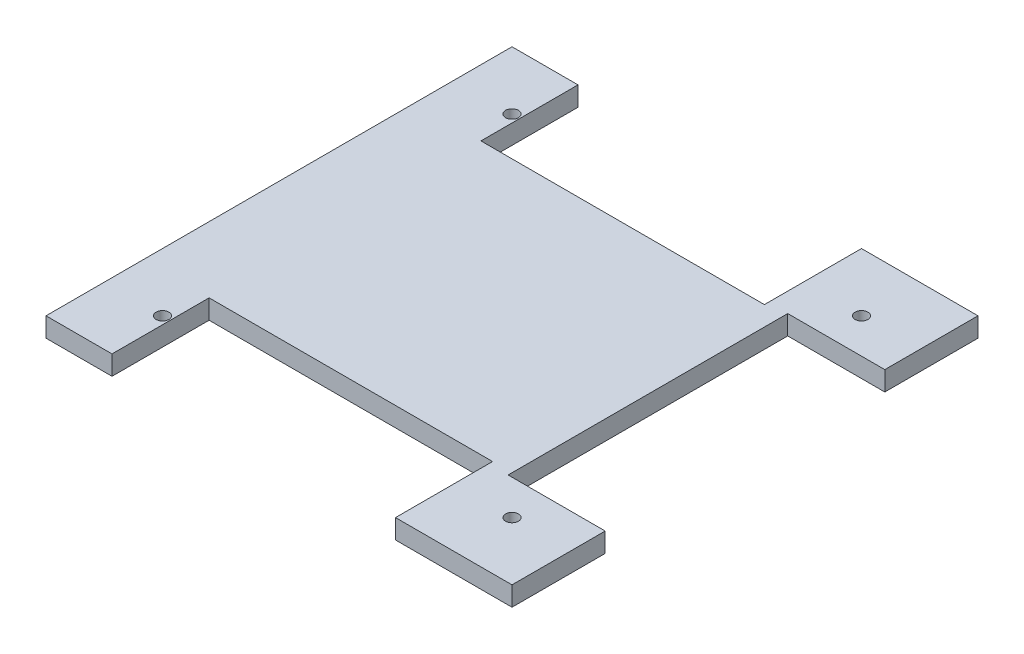
from build123d import *

# Parameters (mm, degrees)
BOSS_EXTRUDE1_DEPTH        = 5
F_3_3_3_3_DIAMETER_HOLE1_D = 3.3


with BuildPart() as part:
    # Sketch1 → Boss-Extrude1 (new body)
    with BuildSketch(Plane(origin=(0, 0, 0), x_dir=(1, 0, 0), z_dir=(0, 1, 0))):
        Polygon((-43, 60), (-43, 35), (30, 35), (30, 60), (60, 60), (60, 36), (35, 36), (35, -36), (60, -36), (60, -60), (30, -60), (30, -35), (-43, -35), (-43, -60), (-60, -60), (-60, 60), align=None)
    extrude(amount=BOSS_EXTRUDE1_DEPTH)

    # Ø3.3 (3.3) Diameter Hole1 (through all)
    with Locations(Plane(origin=(0, 5, 0), x_dir=(1, 0, 0), z_dir=(0, 1, 0))):
        with Locations((-45, 45), (45, 45), (45, -45), (-45, -45)):
            Hole(F_3_3_3_3_DIAMETER_HOLE1_D / 2)


solid = part.part
